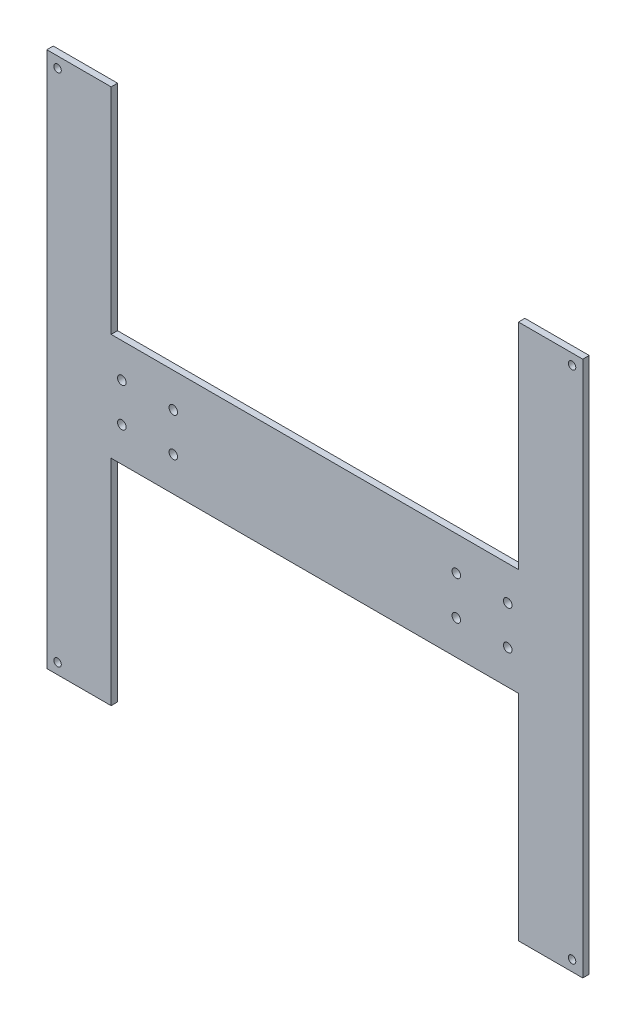
from build123d import *

# Parameters (mm, degrees)
SKETCH1_R           = 2
BOSS_EXTRUDE1_DEPTH = 3
SKETCH3_R           = 1.75
CUT_EXTRUDE1_DEPTH  = 3


with BuildPart() as part:
    # Sketch1 → Boss-Extrude1 (new body)
    with BuildSketch(Plane.XY):
        Polygon((95, 125), (125, 125), (125, -125), (95, -125), (95, -25), (-95, -25), (-95, -125), (-125, -125), (-125, 125), (-95, 125), (-95, 25), (95, 25), align=None)
        with Locations((90, 9)):
            Circle(SKETCH1_R, mode=Mode.SUBTRACT)
        with Locations((90, -9)):
            Circle(SKETCH1_R, mode=Mode.SUBTRACT)
        with Locations((66, 9)):
            Circle(SKETCH1_R, mode=Mode.SUBTRACT)
        with Locations((66, -9)):
            Circle(SKETCH1_R, mode=Mode.SUBTRACT)
        with Locations((-66, -9)):
            Circle(SKETCH1_R, mode=Mode.SUBTRACT)
        with Locations((-66, 9)):
            Circle(SKETCH1_R, mode=Mode.SUBTRACT)
        with Locations((-90, -9)):
            Circle(SKETCH1_R, mode=Mode.SUBTRACT)
        with Locations((-90, 9)):
            Circle(SKETCH1_R, mode=Mode.SUBTRACT)
    extrude(amount=BOSS_EXTRUDE1_DEPTH)

    # Sketch3 → Cut-Extrude1 (cut)
    with BuildSketch(Plane.XY.offset(3)):
        with Locations((-120, 120)):
            Circle(SKETCH3_R)
        with Locations((120, 120)):
            Circle(SKETCH3_R)
        with Locations((-120, -120)):
            Circle(SKETCH3_R)
        with Locations((120, -120)):
            Circle(SKETCH3_R)
    extrude(amount=-CUT_EXTRUDE1_DEPTH, mode=Mode.SUBTRACT)


solid = part.part
